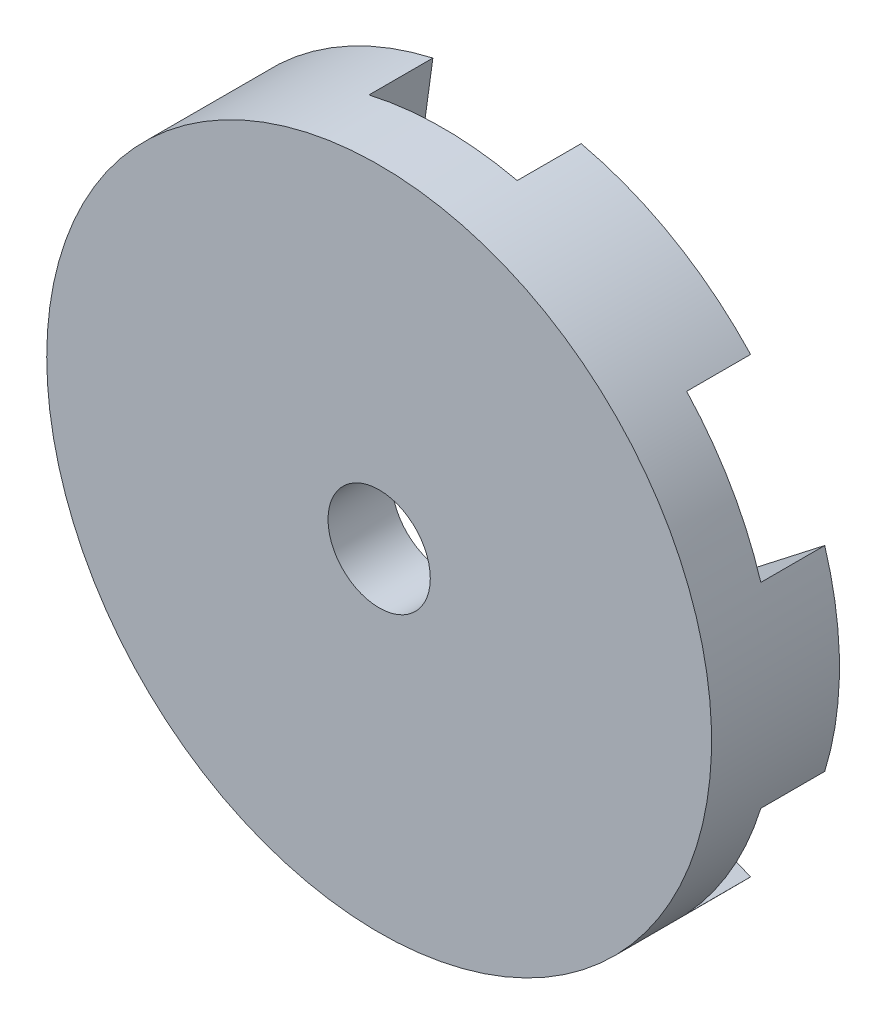
from build123d import *

# Parameters (mm, degrees)
SKETCH_3_R          = 13
EXTRUDE_1_DEPTH     = 5
CUT_EXTRUDE_2_DEPTH = 2.5
SKETCH_6_R          = 2
CUT_EXTRUDE_3_DEPTH = 18
SKETCH_7_R          = 7.5
CUT_EXTRUDE_4_DEPTH = 8
CUT_EXTRUDE_6_DEPTH = 5
FILLET_1_R          = 1
SKETCH_10_W         = 2
SKETCH_10_H         = 13.5
CUT_EXTRUDE_7_DEPTH = 0.5
SKETCH_11_R         = 25
CUT_EXTRUDE_8_DEPTH = 13


with BuildPart() as part:
    # ｽｹｯﾁ3 → ﾎﾞｽ - 押し出し1 (new body)
    with BuildSketch(Plane.XY):
        Circle(SKETCH_3_R)
    extrude(amount=EXTRUDE_1_DEPTH)

    # ｽｹｯﾁ2 → ｶｯﾄ - 押し出し2 (cut)
    with BuildSketch(Plane.XY):
        with BuildLine():
            Line((3.75, 6.495190528), (2.773808556, 13.582081265))
            ThreePointArc((2.773808556, 13.582081265), (0, 16), (-2.773808556, 13.582081265))
            Line((-2.773808556, 13.582081265), (-3.75, 6.495190528))
            Line((-3.75, 6.495190528), (-10.375523134, 9.193229308))
            ThreePointArc((-10.375523134, 9.193229308), (-13.856406461, 8), (-13.14933169, 4.388851958))
            Line((-13.14933169, 4.388851958), (-7.5, 0))
            Line((-7.5, 0), (-13.14933169, -4.388851958))
            ThreePointArc((-13.14933169, -4.388851958), (-13.856406461, -8), (-10.375523134, -9.193229308))
            Line((-10.375523134, -9.193229308), (-3.75, -6.495190528))
            Line((-3.75, -6.495190528), (-2.773808556, -13.582081265))
            ThreePointArc((-2.773808556, -13.582081265), (0, -16), (2.773808556, -13.582081265))
            Line((2.773808556, -13.582081265), (3.75, -6.495190528))
            Line((3.75, -6.495190528), (10.375523134, -9.193229308))
            ThreePointArc((10.375523134, -9.193229308), (13.856406461, -8), (13.14933169, -4.388851958))
            Line((13.14933169, -4.388851958), (7.5, 0))
            Line((7.5, 0), (13.14933169, 4.388851958))
            ThreePointArc((13.14933169, 4.388851958), (13.856406461, 8), (10.375523134, 9.193229308))
            Line((10.375523134, 9.193229308), (3.75, 6.495190528))
        make_face()
    extrude(amount=CUT_EXTRUDE_2_DEPTH, mode=Mode.SUBTRACT)

    # ｽｹｯﾁ5 → 回転1 (revolve)
    with BuildSketch(Plane(origin=(0, 0, 0), x_dir=(1, 0, 0), z_dir=(0, 1, 0))):
        Polygon((0, -5), (25, -5), (25, -7), (10, -7), (10, -15), (25, -15), (25, -17), (0, -17), align=None)
    revolve(axis=Axis((0, 0, 0), (0, 0, 1)))

    # ｽｹｯﾁ6 → ｶｯﾄ - 押し出し3 (cut, through all)
    with BuildSketch(Plane.XY.offset(17)):
        Circle(SKETCH_6_R)
    extrude(amount=-CUT_EXTRUDE_3_DEPTH, mode=Mode.SUBTRACT)

    # ｽｹｯﾁ7 → ｶｯﾄ - 押し出し4 (cut)
    with BuildSketch(Plane.XY.offset(17)):
        Circle(SKETCH_7_R)
    extrude(amount=-CUT_EXTRUDE_4_DEPTH, mode=Mode.SUBTRACT)

    # ｽｹｯﾁ9 → ｶｯﾄ - 押し出し6 (cut)
    with BuildSketch(Plane(origin=(0, 0, 15), x_dir=(-1, 0, 0), z_dir=(0, 0, -1))):
        Polygon((-3.843473937, -0.691164305), (-11.556925253, -9.883697623), (-7.726703038, -13.097635671), (-0.013251721, -3.905102354), align=None)
    cut_extrude_6 = extrude(amount=CUT_EXTRUDE_6_DEPTH, mode=Mode.SUBTRACT)

    # ﾐﾗｰ1: ｶｯﾄ - 押し出し6 across plane
    add(cut_extrude_6.mirror(Plane(origin=(0, 0, 0), x_dir=(0, 0, 1), z_dir=(1, 0, 0))), mode=Mode.SUBTRACT)

    # ﾌｨﾚｯﾄ1
    fillet_1_edges = [part.edges().sort_by_distance(p)[0] for p in [
        (4.308653161, -9.024162451, 12.5),
        (-4.308653161, -9.024162451, 12.5),
    ]]
    fillet(fillet_1_edges, radius=FILLET_1_R)

    # ｽｹｯﾁ10 → ｶｯﾄ - 押し出し7 (cut)
    with BuildSketch(Plane.XY.offset(17)):
        with Locations((0, 16.25)):
            Rectangle(SKETCH_10_W, SKETCH_10_H)
    extrude(amount=-CUT_EXTRUDE_7_DEPTH, mode=Mode.SUBTRACT)

    # ｽｹｯﾁ11 → ｶｯﾄ - 押し出し8 (cut, through all)
    with BuildSketch(Plane(origin=(0, 0, 5), x_dir=(-1, 0, 0), z_dir=(0, 0, -1))):
        Circle(SKETCH_11_R)
    extrude(amount=-CUT_EXTRUDE_8_DEPTH, mode=Mode.SUBTRACT)


solid = part.part
